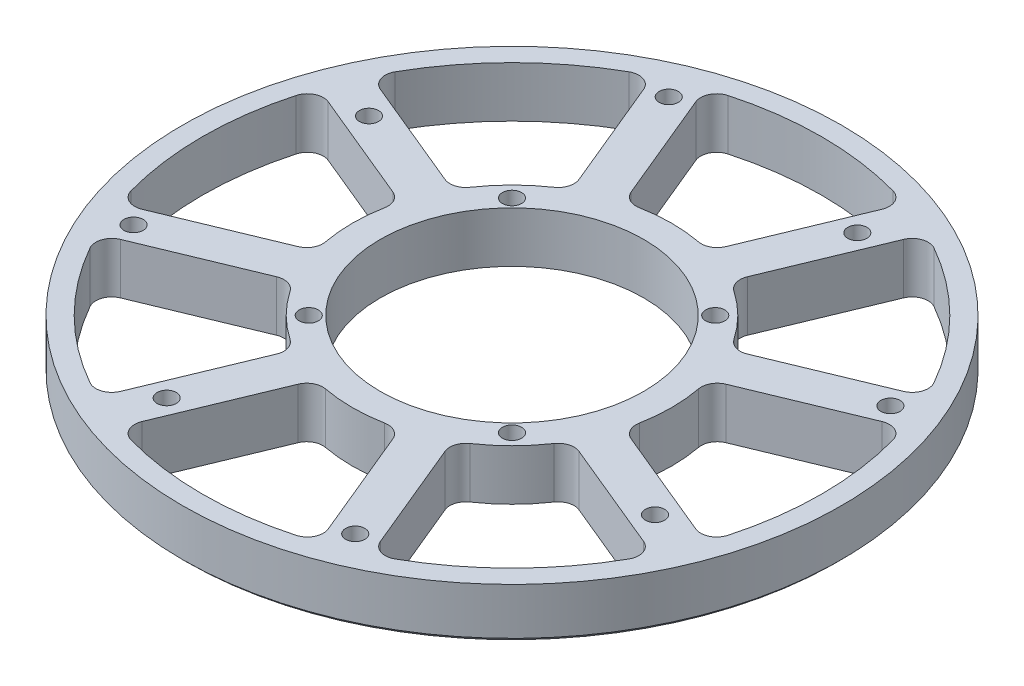
from build123d import *

# Parameters (mm, degrees)
SKETCH2_W                   = 82.55
SKETCH2_H                   = 12.7
F_12_0_189_DIAMETER_HOLE1_D = 4.8006
CIRPATTERN3_COUNT           = 4
CUT_EXTRUDE1_DEPTH          = 13.7
FILLET1_R                   = 4
CIRPATTERN4_COUNT           = 8
FILLET1_OF_CIRPATTERN4_R    = 4
CHAMFER2_SIZE               = 1
SKETCH9_R                   = 33
CUT_EXTRUDE2_DEPTH          = 13.7


with BuildPart() as part:
    # Sketch2 → Revolve1 (revolve)
    with BuildSketch(Plane(origin=(0, 0, 0), x_dir=(0, 0, -1), z_dir=(1, 0, 0))):
        with Locations((-41.275, 6.35)):
            Rectangle(SKETCH2_W, SKETCH2_H)
    revolve(axis=Axis((0, -0.635, 0), (0, 1, 0)))

    # #12 (0.189) Diameter Hole1 (through all)
    with Locations(Plane(origin=(0, 12.7, 0), x_dir=(1, 0, 0), z_dir=(0, 1, 0))):
        with Locations((-27.763683018, 67.027460084), (-61.160825052, 25.333643223), (-25.455844123, 25.455844123)):
            f_12_0_189_diameter_hole1 = Hole(F_12_0_189_DIAMETER_HOLE1_D / 2)

    # CirPattern3: #12 (0.189) Diameter Hole1 ×4 about axis
    cirpattern3_axis = Axis((0, 0, 0), (0, 1, 0))
    for i in range(1, CIRPATTERN3_COUNT):
        add(f_12_0_189_diameter_hole1.rotate(cirpattern3_axis, i * 360 / CIRPATTERN3_COUNT), mode=Mode.SUBTRACT)

    # Sketch8 → Cut-Extrude1 (cut, through all)
    with BuildSketch(Plane(origin=(0, 12.7, 0), x_dir=(1, 0, 0), z_dir=(0, 1, 0))):
        with BuildLine():
            Line((-10.567880231, 38.578749428), (-24.995954941, 73.411203073))
            ThreePointArc((-24.995954941, 73.411203073), (0, 77.55), (24.995954941, 73.411203073))
            Line((24.995954941, 73.411203073), (10.567880231, 38.578749428))
            ThreePointArc((10.567880231, 38.578749428), (0, 40), (-10.567880231, 38.578749428))
        make_face()
    cut_extrude1 = extrude(amount=-CUT_EXTRUDE1_DEPTH, mode=Mode.SUBTRACT)

    # Fillet1
    fillet1_edges = [part.edges().sort_by_distance(p)[0] for p in [
        (10.567880231, 6.35, -38.578749428),
        (-10.567880231, 6.35, -38.578749428),
        (-24.995954941, 6.35, -73.411203073),
        (24.995954941, 6.35, -73.411203073),
    ]]
    fillet(fillet1_edges, radius=FILLET1_R)

    # CirPattern4: Cut-Extrude1 ×8 about axis
    cirpattern4_axis = Axis((0, 0, 0), (0, 1, 0))
    for i in range(1, CIRPATTERN4_COUNT):
        add(cut_extrude1.rotate(cirpattern4_axis, i * 360 / CIRPATTERN4_COUNT), mode=Mode.SUBTRACT)

    # Fillet1 of CirPattern4
    fillet1_of_cirpattern4_edges = [part.edges().sort_by_distance(p)[0] for p in [
        (-19.806675556, 6.35, -34.751915104),
        (-34.751915104, 6.35, -19.806675556),
        (-69.584368749, 6.35, -34.234750266),
        (-34.234750266, 6.35, -69.584368749),
        (-38.578749428, 6.35, -10.567880231),
        (-38.578749428, 6.35, 10.567880231),
        (-73.411203073, 6.35, 24.995954941),
        (-73.411203073, 6.35, -24.995954941),
        (-34.751915104, 6.35, 19.806675556),
        (-19.806675556, 6.35, 34.751915104),
        (-34.234750266, 6.35, 69.584368749),
        (-69.584368749, 6.35, 34.234750266),
        (-10.567880231, 6.35, 38.578749428),
        (10.567880231, 6.35, 38.578749428),
        (24.995954941, 6.35, 73.411203073),
        (-24.995954941, 6.35, 73.411203073),
        (19.806675556, 6.35, 34.751915104),
        (34.751915104, 6.35, 19.806675556),
        (69.584368749, 6.35, 34.234750266),
        (34.234750266, 6.35, 69.584368749),
        (38.578749428, 6.35, 10.567880231),
        (38.578749428, 6.35, -10.567880231),
        (73.411203073, 6.35, -24.995954941),
        (73.411203073, 6.35, 24.995954941),
        (34.751915104, 6.35, -19.806675556),
        (19.806675556, 6.35, -34.751915104),
        (34.234750266, 6.35, -69.584368749),
        (69.584368749, 6.35, -34.234750266),
    ]]
    fillet(fillet1_of_cirpattern4_edges, radius=FILLET1_OF_CIRPATTERN4_R)

    # Chamfer2
    chamfer2_edges = [part.edges().sort_by_distance(p)[0] for p in [
        (0, 0, -82.55),
    ]]
    chamfer(chamfer2_edges, length=CHAMFER2_SIZE)

    # Sketch9 → Cut-Extrude2 (cut, through all)
    with BuildSketch(Plane(origin=(0, 12.7, 0), x_dir=(1, 0, 0), z_dir=(0, 1, 0))):
        Circle(SKETCH9_R)
    extrude(amount=-CUT_EXTRUDE2_DEPTH, mode=Mode.SUBTRACT)


solid = part.part
